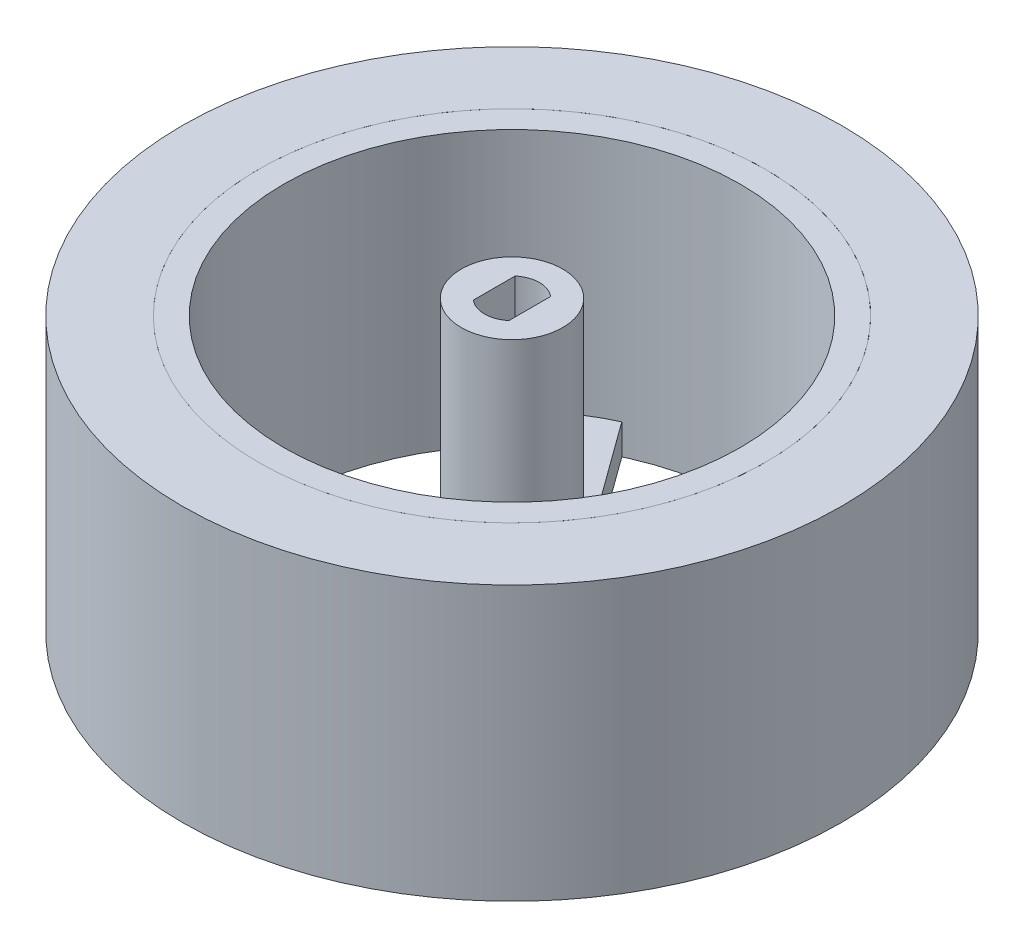
from build123d import *

# Parameters (mm, degrees)
SKETCH1_R           = 32.5
SKETCH1_R_2         = 25
BOSS_EXTRUDE1_DEPTH = 27
SKETCH2_R           = 25
SKETCH2_R_2         = 22.5
BOSS_EXTRUDE2_DEPTH = 27
BOSS_EXTRUDE3_DEPTH = 3
SKETCH4_R           = 0.75
CUT_EXTRUDE1_DEPTH  = 3
SKETCH5_R           = 5
BOSS_EXTRUDE4_DEPTH = 25.5


with BuildPart() as part:
    # Sketch1 → Boss-Extrude1 (new body)
    with BuildSketch(Plane(origin=(0, 0, 0), x_dir=(1, 0, 0), z_dir=(0, 1, 0))):
        Circle(SKETCH1_R)
        Circle(SKETCH1_R_2, mode=Mode.SUBTRACT)
    extrude(amount=BOSS_EXTRUDE1_DEPTH)


with BuildPart() as body_2:
    # Sketch2 → Boss-Extrude2 (new body)
    with BuildSketch(Plane.XZ):
        Circle(SKETCH2_R)
        Circle(SKETCH2_R_2, mode=Mode.SUBTRACT)
    extrude(amount=-BOSS_EXTRUDE2_DEPTH)


with BuildPart() as body_3:
    # Sketch3 → Boss-Extrude3 (new body)
    with BuildSketch(Plane.XZ):
        with BuildLine():
            Line((4.25, 8.036806053), (6.330134541, 6.525499845))
            Line((6.330134541, 6.525499845), (19.70023868, 10.869710021))
            ThreePointArc((19.70023868, 10.869710021), (20.438539496, 9.408299702), (21.068609586, 7.897068451))
            Line((21.068609586, 7.897068451), (8.250491652, 3.732209466))
            Line((8.250491652, 3.732209466), (8.868525641, 1.830096433))
            Line((8.868525641, 1.830096433), (21.686643575, 5.994955418))
            ThreePointArc((21.686643575, 5.994955418), (22.065185606, 4.401997747), (22.326883133, 2.785729632))
            Line((22.326883133, 2.785729632), (8.956778993, -1.558480543))
            Line((8.956778993, -1.558480543), (8.1622383, -4.003825356))
            Line((8.1622383, -4.003825356), (16.425417091, -15.377115249))
            ThreePointArc((16.425417091, -15.377115249), (15.263680783, -16.530881675), (14.02111682, -17.597110079))
            Line((14.02111682, -17.597110079), (6.099084265, -6.693367697))
            Line((6.099084265, -6.693367697), (4.481050276, -7.868938202))
            Line((4.481050276, -7.868938202), (12.403082831, -18.772680583))
            ThreePointArc((12.403082831, -18.772680583), (11.005065978, -19.624946441), (9.548772639, -20.373289894))
            Line((9.548772639, -20.373289894), (1.285593848, -9))
            Line((1.285593848, -9), (-1.285593848, -9))
            Line((-1.285593848, -9), (-9.548772639, -20.373289894))
            ThreePointArc((-9.548772639, -20.373289894), (-11.005065978, -19.624946441), (-12.403082831, -18.772680583))
            Line((-12.403082831, -18.772680583), (-4.481050276, -7.868938202))
            Line((-4.481050276, -7.868938202), (-6.099084265, -6.693367697))
            Line((-6.099084265, -6.693367697), (-14.02111682, -17.597110079))
            ThreePointArc((-14.02111682, -17.597110079), (-15.263680783, -16.530881675), (-16.425417091, -15.377115249))
            Line((-16.425417091, -15.377115249), (-8.1622383, -4.003825356))
            Line((-8.1622383, -4.003825356), (-8.956778993, -1.558480543))
            Line((-8.956778993, -1.558480543), (-22.326883133, 2.785729632))
            ThreePointArc((-22.326883133, 2.785729632), (-22.065185606, 4.401997747), (-21.686643575, 5.994955418))
            Line((-21.686643575, 5.994955418), (-8.868525641, 1.830096433))
            Line((-8.868525641, 1.830096433), (-8.250491652, 3.732209466))
            Line((-8.250491652, 3.732209466), (-21.068609586, 7.897068451))
            ThreePointArc((-21.068609586, 7.897068451), (-20.438539496, 9.408299702), (-19.70023868, 10.869710021))
            Line((-19.70023868, 10.869710021), (-6.330134541, 6.525499845))
            Line((-6.330134541, 6.525499845), (-4.25, 8.036806053))
            Line((-4.25, 8.036806053), (-4.25, 22.09496549))
            ThreePointArc((-4.25, 22.09496549), (-2.631968695, 22.345530667), (-1, 22.477766793))
            Line((-1, 22.477766793), (-1, 9))
            Line((-1, 9), (1, 9))
            Line((1, 9), (1, 22.477766793))
            ThreePointArc((1, 22.477766793), (2.631968695, 22.345530667), (4.25, 22.09496549))
            Line((4.25, 22.09496549), (4.25, 8.036806053))
        make_face()
    extrude(amount=-BOSS_EXTRUDE3_DEPTH)

    # Sketch4 → Cut-Extrude1 (cut)
    with BuildSketch(Plane.XZ):
        Circle(SKETCH4_R)
    extrude(amount=-CUT_EXTRUDE1_DEPTH, mode=Mode.SUBTRACT)


with BuildPart() as body_4:
    # Sketch5 → Boss-Extrude4 (new body)
    with BuildSketch(Plane(origin=(0, 3, 0), x_dir=(1, 0, 0), z_dir=(0, 1, 0))):
        Circle(SKETCH5_R)
        with BuildLine():
            Line((1.75, 2.056088519), (1.75, -2.056088519))
            ThreePointArc((1.75, -2.056088519), (0, -2.7), (-1.75, -2.056088519))
            Line((-1.75, -2.056088519), (-1.75, 2.056088519))
            ThreePointArc((-1.75, 2.056088519), (0, 2.7), (1.75, 2.056088519))
        make_face(mode=Mode.SUBTRACT)
    extrude(amount=BOSS_EXTRUDE4_DEPTH)


solid = Compound([part.part, body_2.part, body_3.part, body_4.part])
